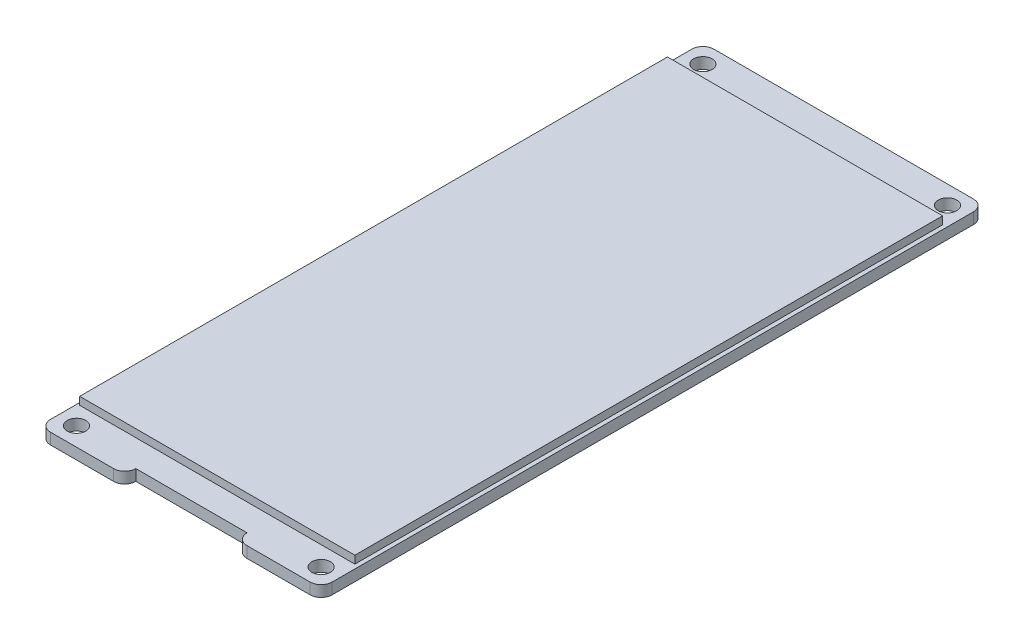
from build123d import *

# Parameters (mm, degrees)
SKETCH1_R           = 1.25
BOSS_EXTRUDE1_DEPTH = 1.5
SKETCH2_W           = 37.118680969
SKETCH2_H           = 79.295382989
BOSS_EXTRUDE2_DEPTH = 1.05
SKETCH3_R           = 1.480960071
SKETCH3_W           = 0.706323155
SKETCH3_H           = 2.007969185
SKETCH3_W_2         = 1.202782264
SKETCH3_H_2         = 2.785488108
SKETCH3_W_3         = 1.512629418
SKETCH3_H_3         = 4.544655772
SKETCH3_W_4         = 1.362329437
SKETCH3_W_5         = 1.179692139
SKETCH3_W_6         = 1.879481301
SKETCH3_H_4         = 1.158224536
BOSS_EXTRUDE3_DEPTH = 1


with BuildPart() as part:
    # Sketch1 → Boss-Extrude1 (new body)
    with BuildSketch(Plane(origin=(0, 0, 0), x_dir=(1, 0, 0), z_dir=(0, 1, 0))):
        with BuildLine():
            Line((1.5, 0), (10, 0))
            ThreePointArc((10, 0), (11.060660172, 0.439339828), (11.5, 1.5))
            Line((11.5, 1.5), (26.5, 1.5))
            ThreePointArc((26.5, 1.5), (26.939339828, 0.439339828), (28, 0))
            Line((28, 0), (36.5, 0))
            ThreePointArc((36.5, 0), (37.560660172, 0.439339828), (38, 1.5))
            Line((38, 1.5), (38, 88))
            ThreePointArc((38, 88), (37.560660172, 89.060660172), (36.5, 89.5))
            Line((36.5, 89.5), (1.5, 89.5))
            ThreePointArc((1.5, 89.5), (0.439339828, 89.060660172), (0, 88))
            Line((0, 88), (0, 1.5))
            ThreePointArc((0, 1.5), (0.439339828, 0.439339828), (1.5, 0))
        make_face()
        with Locations((2.5, 2.5)):
            Circle(SKETCH1_R, mode=Mode.SUBTRACT)
        with Locations((35.5, 2.5)):
            Circle(SKETCH1_R, mode=Mode.SUBTRACT)
        with Locations((35.5, 87)):
            Circle(SKETCH1_R, mode=Mode.SUBTRACT)
        with Locations((2.5, 87)):
            Circle(SKETCH1_R, mode=Mode.SUBTRACT)
    extrude(amount=BOSS_EXTRUDE1_DEPTH)

    # Sketch2 → Boss-Extrude2 (add)
    with BuildSketch(Plane(origin=(0, 1.5, 0), x_dir=(1, 0, 0), z_dir=(0, 1, 0))):
        with Locations((18.880991901, 44.755610098)):
            Rectangle(SKETCH2_W, SKETCH2_H)
    extrude(amount=BOSS_EXTRUDE2_DEPTH)

    # Sketch3 → Boss-Extrude3 (add)
    with BuildSketch(Plane.XZ):
        with Locations((13.144272763, -26.539340378)):
            Circle(SKETCH3_R)
        with Locations((23.149698331, -19.663516122)):
            Rectangle(SKETCH3_W, SKETCH3_H)
        with Locations((14.4411934, -40.235350725)):
            Rectangle(SKETCH3_W_2, SKETCH3_H_2)
        with Locations((17.469755638, -26.538684778)):
            Rectangle(SKETCH3_W_3, SKETCH3_H_3)
        with Locations((20.813975953, -26.538684778)):
            Rectangle(SKETCH3_W_4, SKETCH3_H_3)
        with Locations((24.294071036, -26.538684778)):
            Rectangle(SKETCH3_W_5, SKETCH3_H_3)
        with Locations((24.999698331, -19.663516122)):
            Rectangle(SKETCH3_W, SKETCH3_H)
        with Locations((21.299698331, -19.663516122)):
            Rectangle(SKETCH3_W, SKETCH3_H)
        with Locations((19.449698331, -19.663516122)):
            Rectangle(SKETCH3_W, SKETCH3_H)
        with Locations((17.599698331, -19.663516122)):
            Rectangle(SKETCH3_W, SKETCH3_H)
        with Locations((15.749698331, -19.663516122)):
            Rectangle(SKETCH3_W, SKETCH3_H)
        with Locations((12.900061618, -19.576771436)):
            Rectangle(SKETCH3_W_6, SKETCH3_H_4)
        with Locations((23.149698331, -15.063516122)):
            Rectangle(SKETCH3_W, SKETCH3_H)
        with Locations((21.299698331, -15.063516122)):
            Rectangle(SKETCH3_W, SKETCH3_H)
        with Locations((19.449698331, -15.063516122)):
            Rectangle(SKETCH3_W, SKETCH3_H)
        with Locations((17.599698331, -15.063516122)):
            Rectangle(SKETCH3_W, SKETCH3_H)
        with Locations((15.749698331, -15.063516122)):
            Rectangle(SKETCH3_W, SKETCH3_H)
        with Locations((13.899698331, -15.063516122)):
            Rectangle(SKETCH3_W, SKETCH3_H)
        with Locations((12.049698331, -15.063516122)):
            Rectangle(SKETCH3_W, SKETCH3_H)
        with Locations((24.999698331, -15.063516122)):
            Rectangle(SKETCH3_W, SKETCH3_H)
    extrude(amount=BOSS_EXTRUDE3_DEPTH)


solid = part.part
